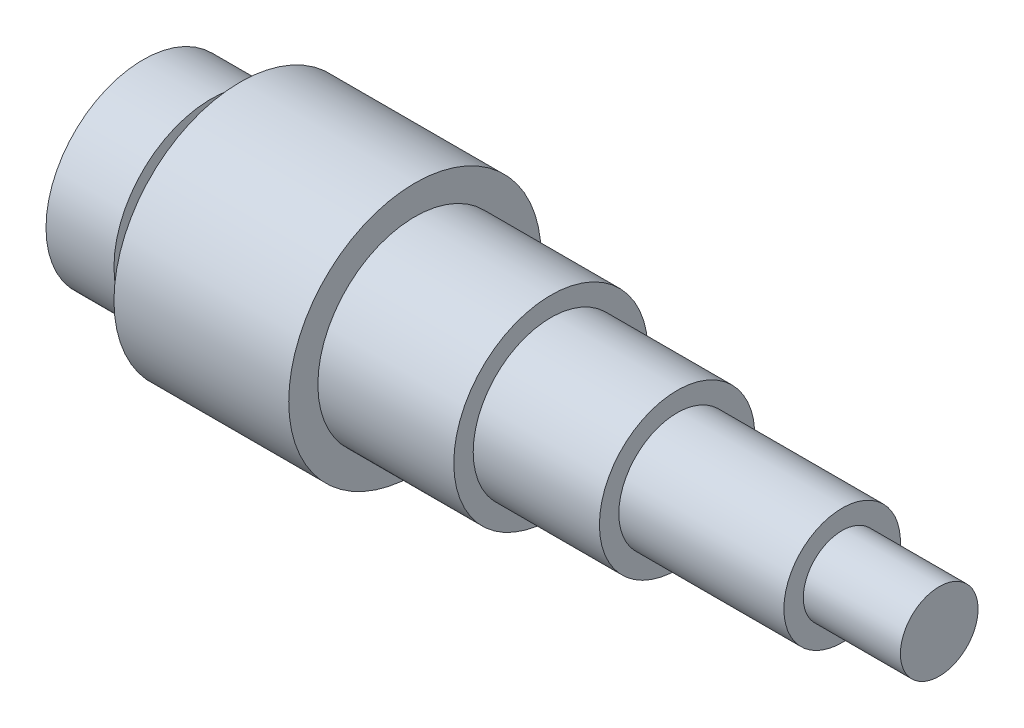
from build123d import *

# Parameters (mm, degrees)
SKETCH1_W          = 3
SKETCH1_H          = 8
SKETCH1_W_2        = 10
SKETCH1_H_2        = 4
SKETCH2_R          = 2.5
CUT_EXTRUDE1_DEPTH = 36


with BuildPart() as part:
    # Sketch1 → Revolve2 (revolve)
    with BuildSketch(Plane(origin=(0, 0, 0), x_dir=(1, 0, 0), z_dir=(0, 1, 0))):
        Polygon((3.5, 0), (-3.5, 0), (-3.5, -10), (3.5, -10), (3.5, -8), align=None)
        with Locations((5, -4)):
            Rectangle(SKETCH1_W, SKETCH1_H)
        Polygon((24.5, 0), (6.5, 0), (6.5, -8), (6.5, -13), (24.5, -13), (24.5, -10), align=None)
        Polygon((38.5, 0), (24.5, 0), (24.5, -10), (38.5, -10), (38.5, -8), align=None)
        Polygon((51.5, 0), (38.5, 0), (38.5, -8), (51.5, -8), (51.5, -6), align=None)
        Polygon((68.5, 0), (51.5, 0), (51.5, -6), (68.5, -6), (68.5, -4), align=None)
        with Locations((73.5, -2)):
            Rectangle(SKETCH1_W_2, SKETCH1_H_2)
    revolve(axis=Axis((-3.5, 0, 0), (1, 0, 0)))

    # Sketch2 → Cut-Extrude1 (cut)
    with BuildSketch(Plane.ZY.offset(3.5)):
        Circle(SKETCH2_R)
    extrude(amount=-CUT_EXTRUDE1_DEPTH, mode=Mode.SUBTRACT)

    # Sketch3 → Cut-Revolve2 (revolve, cut)
    with BuildSketch(Plane.XY):
        Polygon((32.5, 0), (34.5, 0), (32.5, -2.5), align=None)
    revolve(axis=Axis((34.5, 0, 0), (-1, 0, 0)), mode=Mode.SUBTRACT)


solid = part.part
